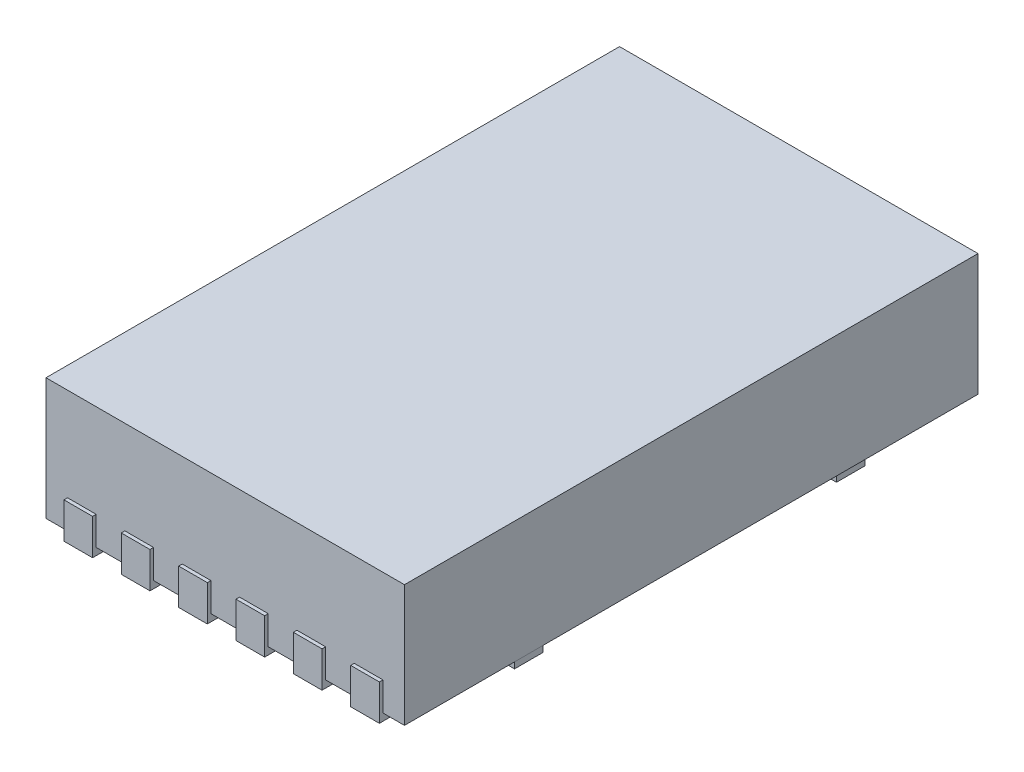
from build123d import *

# Parameters (mm, degrees)
SKETCH1_W           = 2.5
SKETCH1_H           = 4
BOSS_EXTRUDE1_DEPTH = 0.85
BOSS_EXTRUDE2_START = -0.2
BOSS_EXTRUDE2_DEPTH = 0.25
BOSS_EXTRUDE3_DEPTH = 0.05


with BuildPart() as part:
    # Sketch1 → Boss-Extrude1 (new body)
    with BuildSketch(Plane(origin=(0, 0, 0), x_dir=(1, 0, 0), z_dir=(0, 1, 0))):
        with Locations((1.25, 2)):
            Rectangle(SKETCH1_W, SKETCH1_H)
    extrude(amount=BOSS_EXTRUDE1_DEPTH)

    # Sketch2 → Boss-Extrude2 (add)
    with BuildSketch(Plane.XZ.offset(BOSS_EXTRUDE2_START)):
        with BuildLine():
            Line((1.75, 0.025), (1.75, -0.332105814))
            ThreePointArc((1.75, -0.332105814), (1.85, -0.4), (1.95, -0.332105814))
            Line((1.95, -0.332105814), (1.95, 0.025))
            Line((1.95, 0.025), (1.75, 0.025))
        make_face()
        with BuildLine():
            Line((1.35, 0.025), (1.35, -0.332105814))
            ThreePointArc((1.35, -0.332105814), (1.45, -0.4), (1.55, -0.332105814))
            Line((1.55, -0.332105814), (1.55, 0.025))
            Line((1.55, 0.025), (1.35, 0.025))
        make_face()
        with BuildLine():
            Line((2.15, 0.025), (2.15, -0.332105814))
            ThreePointArc((2.15, -0.332105814), (2.25, -0.4), (2.35, -0.332105814))
            Line((2.35, -0.332105814), (2.35, 0.025))
            Line((2.35, 0.025), (2.15, 0.025))
        make_face()
        with BuildLine():
            Line((0.95, 0.025), (0.95, -0.332105814))
            ThreePointArc((0.95, -0.332105814), (1.05, -0.4), (1.15, -0.332105814))
            Line((1.15, -0.332105814), (1.15, 0.025))
            Line((1.15, 0.025), (0.95, 0.025))
        make_face()
        with BuildLine():
            Line((0.55, 0.025), (0.55, -0.332105814))
            ThreePointArc((0.55, -0.332105814), (0.65, -0.4), (0.75, -0.332105814))
            Line((0.75, -0.332105814), (0.75, 0.025))
            Line((0.75, 0.025), (0.55, 0.025))
        make_face()
        with BuildLine():
            Line((0.15, 0.025), (0.15, -0.332105814))
            ThreePointArc((0.15, -0.332105814), (0.25, -0.4), (0.35, -0.332105814))
            Line((0.35, -0.332105814), (0.35, 0.025))
            Line((0.35, 0.025), (0.15, 0.025))
        make_face()
    boss_extrude2 = extrude(amount=BOSS_EXTRUDE2_DEPTH)

    # Mirror1: Boss-Extrude2 across plane
    add(boss_extrude2.mirror(Plane.XY.offset(-2)))

    # Sketch4 → Boss-Extrude3 (add)
    with BuildSketch(Plane.XZ):
        Polygon((2.488245591, -3.025), (2.225, -3.025), (2.225, -0.975), (2.492493394, -0.975), (2.492493394, -0.775), (1.25, -0.775), (0.00934793, -0.775), (0.00934793, -0.975), (0.275, -0.975), (0.275, -2), (0.275, -3.025), (0.00934793, -3.025), (0.00934793, -3.225), (1.25, -3.225), (2.488245591, -3.225), align=None)
    extrude(amount=BOSS_EXTRUDE3_DEPTH)


solid = part.part
